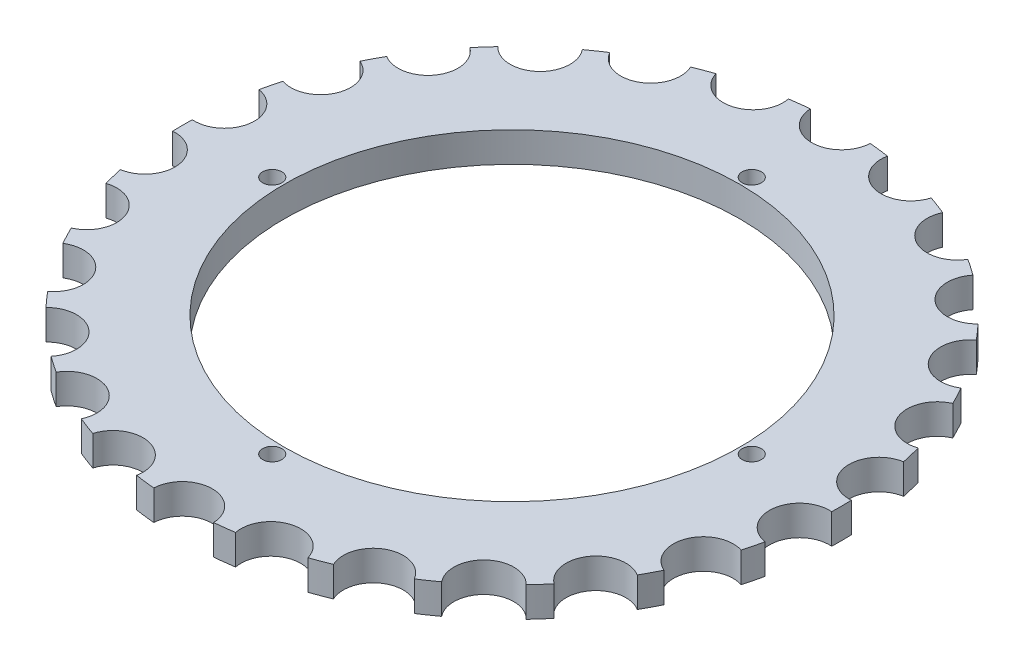
from build123d import *

# Parameters (mm, degrees)
ESQUISSE1_R        = 0.16
BOSS_EXTRU_1_DEPTH = 0.5


with BuildPart() as part:
    # Esquisse1 → Boss.-Extru.1 (new body)
    with BuildSketch(Plane(origin=(0, 0, 0), x_dir=(1, 0, 0), z_dir=(0, 1, 0))):
        with BuildLine():
            ThreePointArc((5.497543289, -0.164370862), (5.499385788, -0.08219461), (5.5, 0))
            ThreePointArc((5.5, 0), (5.499385788, 0.08219461), (5.497543289, 0.164370862))
            ThreePointArc((5.497543289, 0.164370862), (4.96354437, 0.602683401), (5.377131195, 1.15605368))
            ThreePointArc((5.377131195, 1.15605368), (5.340179996, 1.316236154), (5.298458151, 1.475242768))
            ThreePointArc((5.298458151, 1.475242768), (4.675081213, 1.773024435), (4.94421978, 2.409292585))
            ThreePointArc((4.94421978, 2.409292585), (4.870008141, 2.555977446), (4.791445883, 2.700378926))
            ThreePointArc((4.791445883, 2.700378926), (4.114919329, 2.840323734), (4.223968284, 3.522512163))
            ThreePointArc((4.223968284, 3.522512163), (4.116809115, 3.64717462), (4.005972198, 3.768578877))
            ThreePointArc((4.005972198, 3.768578877), (3.315613291, 3.742553741), (3.258235104, 4.431016137))
            ThreePointArc((3.258235104, 4.431016137), (3.124356107, 4.526411262), (2.987685969, 4.617762722))
            ThreePointArc((2.987685969, 4.617762722), (2.32361586, 4.427280128), (2.103145143, 5.082005559))
            ThreePointArc((2.103145143, 5.082005559), (1.950326879, 5.142589335), (1.795766291, 5.198578982))
            ThreePointArc((1.795766291, 5.198578982), (1.196578321, 4.854709087), (0.825828031, 5.437647291))
            ThreePointArc((0.825828031, 5.437647291), (0.662951741, 5.459898808), (0.499483204, 5.477272727))
            ThreePointArc((0.499483204, 5.477272727), (0, 5), (-0.499483204, 5.477272727))
            ThreePointArc((-0.499483204, 5.477272727), (-0.662951741, 5.459898808), (-0.825828031, 5.437647291))
            ThreePointArc((-0.825828031, 5.437647291), (-0.818639901, 5.389149062), (-0.816236154, 5.340179996))
            ThreePointArc((-0.816236154, 5.340179996), (-1.24469969, 4.845323921), (-1.795766291, 5.198578982))
            ThreePointArc((-1.795766291, 5.198578982), (-1.950326879, 5.142589335), (-2.103145143, 5.082005559))
            ThreePointArc((-2.103145143, 5.082005559), (-2.067911799, 4.978598768), (-2.055977446, 4.870008141))
            ThreePointArc((-2.055977446, 4.870008141), (-2.425314256, 4.387382892), (-2.987685969, 4.617762722))
            ThreePointArc((-2.987685969, 4.617762722), (-3.124356107, 4.526411262), (-3.258235104, 4.431016137))
            ThreePointArc((-3.258235104, 4.431016137), (-3.175756675, 4.283437807), (-3.14717462, 4.116809115))
            ThreePointArc((-3.14717462, 4.116809115), (-3.459290066, 3.653452455), (-4.005972198, 3.768578877))
            ThreePointArc((-4.005972198, 3.768578877), (-4.116809115, 3.64717462), (-4.223968284, 3.522512163))
            ThreePointArc((-4.223968284, 3.522512163), (-4.078515354, 3.346593042), (-4.026411262, 3.124356107))
            ThreePointArc((-4.026411262, 3.124356107), (-4.284045125, 2.687024819), (-4.791445883, 2.700378926))
            ThreePointArc((-4.791445883, 2.700378926), (-4.870008141, 2.555977446), (-4.94421978, 2.409292585))
            ThreePointArc((-4.94421978, 2.409292585), (-4.724746794, 2.224931342), (-4.642589335, 1.950326879))
            ThreePointArc((-4.642589335, 1.950326879), (-4.849275857, 1.545398238), (-5.298458151, 1.475242768))
            ThreePointArc((-5.298458151, 1.475242768), (-5.340179996, 1.316236154), (-5.377131195, 1.15605368))
            ThreePointArc((-5.377131195, 1.15605368), (-5.07820272, 0.985919382), (-4.959898808, 0.662951741))
            ThreePointArc((-4.959898808, 0.662951741), (-5.119915162, 0.296330519), (-5.497543289, 0.164370862))
            ThreePointArc((-5.497543289, 0.164370862), (-5.5, 0), (-5.497543289, -0.164370862))
            ThreePointArc((-5.497543289, -0.164370862), (-5.119915162, -0.296330519), (-4.959898808, -0.662951741))
            ThreePointArc((-4.959898808, -0.662951741), (-5.07820272, -0.985919382), (-5.377131195, -1.15605368))
            ThreePointArc((-5.377131195, -1.15605368), (-5.340179996, -1.316236154), (-5.298458151, -1.475242768))
            ThreePointArc((-5.298458151, -1.475242768), (-4.849275857, -1.545398238), (-4.642589335, -1.950326879))
            ThreePointArc((-4.642589335, -1.950326879), (-4.724746794, -2.224931342), (-4.94421978, -2.409292585))
            ThreePointArc((-4.94421978, -2.409292585), (-4.870008141, -2.555977446), (-4.791445883, -2.700378926))
            ThreePointArc((-4.791445883, -2.700378926), (-4.284045125, -2.687024819), (-4.026411262, -3.124356107))
            ThreePointArc((-4.026411262, -3.124356107), (-4.078515354, -3.346593042), (-4.223968284, -3.522512163))
            ThreePointArc((-4.223968284, -3.522512163), (-4.116809115, -3.64717462), (-4.005972198, -3.768578877))
            ThreePointArc((-4.005972198, -3.768578877), (-3.459290066, -3.653452455), (-3.14717462, -4.116809115))
            ThreePointArc((-3.14717462, -4.116809115), (-3.175756675, -4.283437807), (-3.258235104, -4.431016137))
            ThreePointArc((-3.258235104, -4.431016137), (-3.124356107, -4.526411262), (-2.987685969, -4.617762722))
            ThreePointArc((-2.987685969, -4.617762722), (-2.425314256, -4.387382892), (-2.055977446, -4.870008141))
            ThreePointArc((-2.055977446, -4.870008141), (-2.067911799, -4.978598768), (-2.103145143, -5.082005559))
            ThreePointArc((-2.103145143, -5.082005559), (-1.950326879, -5.142589335), (-1.795766291, -5.198578982))
            ThreePointArc((-1.795766291, -5.198578982), (-1.24469969, -4.845323921), (-0.816236154, -5.340179996))
            ThreePointArc((-0.816236154, -5.340179996), (-0.818639901, -5.389149062), (-0.825828031, -5.437647291))
            ThreePointArc((-0.825828031, -5.437647291), (-0.662951741, -5.459898808), (-0.499483204, -5.477272727))
            ThreePointArc((-0.499483204, -5.477272727), (0, -5), (0.499483204, -5.477272727))
            ThreePointArc((0.499483204, -5.477272727), (0.662951741, -5.459898808), (0.825828031, -5.437647291))
            ThreePointArc((0.825828031, -5.437647291), (1.196578321, -4.854709087), (1.795766291, -5.198578982))
            ThreePointArc((1.795766291, -5.198578982), (1.950326879, -5.142589335), (2.103145143, -5.082005559))
            ThreePointArc((2.103145143, -5.082005559), (2.32361586, -4.427280128), (2.987685969, -4.617762722))
            ThreePointArc((2.987685969, -4.617762722), (3.124356107, -4.526411262), (3.258235104, -4.431016137))
            ThreePointArc((3.258235104, -4.431016137), (3.315613291, -3.742553741), (4.005972198, -3.768578877))
            ThreePointArc((4.005972198, -3.768578877), (4.116809115, -3.64717462), (4.223968284, -3.522512163))
            ThreePointArc((4.223968284, -3.522512163), (4.114919329, -2.840323734), (4.791445883, -2.700378926))
            ThreePointArc((4.791445883, -2.700378926), (4.870008141, -2.555977446), (4.94421978, -2.409292585))
            ThreePointArc((4.94421978, -2.409292585), (4.675081213, -1.773024435), (5.298458151, -1.475242768))
            ThreePointArc((5.298458151, -1.475242768), (5.340179996, -1.316236154), (5.377131195, -1.15605368))
            ThreePointArc((5.377131195, -1.15605368), (4.96354437, -0.602683401), (5.497543289, -0.164370862))
        make_face()
        with Locations((0, -4)):
            Circle(ESQUISSE1_R, mode=Mode.SUBTRACT)
        with Locations((-4, 0)):
            Circle(ESQUISSE1_R, mode=Mode.SUBTRACT)
        with BuildLine():
            ThreePointArc((3.8, 0), (-2.687005769, -2.687005769), (0, 3.8))
            ThreePointArc((0, 3.8), (2.687005769, 2.687005769), (3.8, 0))
        make_face(mode=Mode.SUBTRACT)
        with BuildLine():
            ThreePointArc((0.16, 4), (0.113137085, 3.886862915), (0, 3.84))
            ThreePointArc((0, 3.84), (-0.113137085, 4.113137085), (0.16, 4))
        make_face(mode=Mode.SUBTRACT)
        with Locations((4, 0)):
            Circle(ESQUISSE1_R, mode=Mode.SUBTRACT)
    extrude(amount=BOSS_EXTRU_1_DEPTH)


solid = part.part
